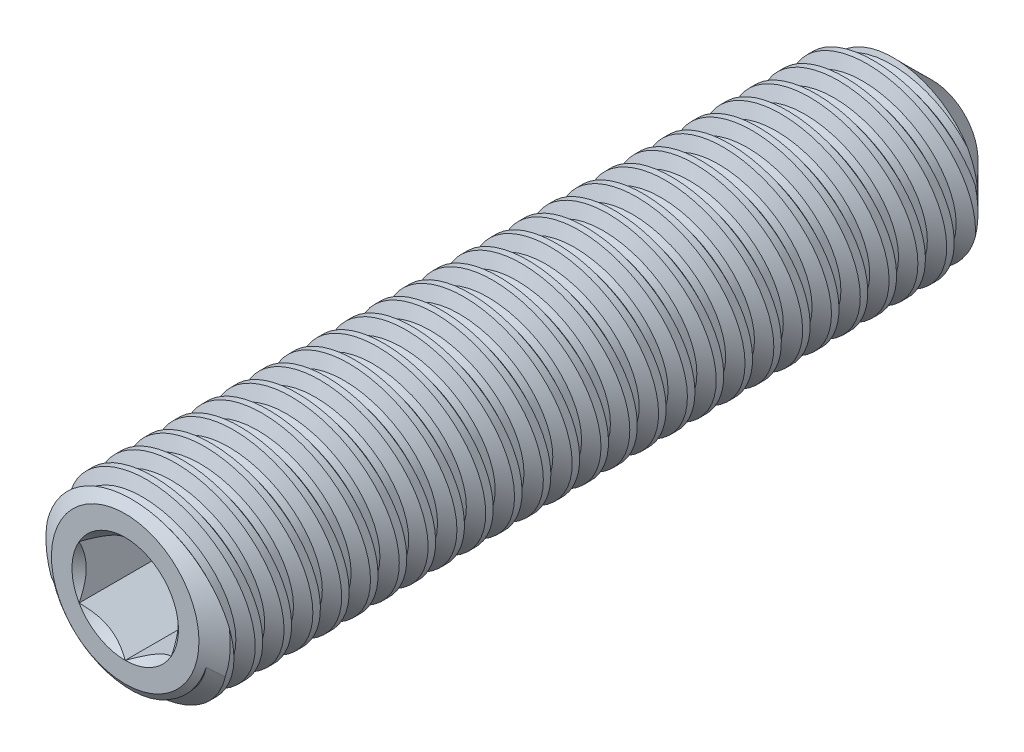
from build123d import *

# Parameters (mm, degrees)
LPATTERN1_COUNT     = 27
LPATTERN1_PITCH     = 1.25
LPATTERN1_COL_COUNT = 2
LPATTERN1_COL_PITCH = 1.25
CUT_EXTRUDE10_DEPTH = 4


with BuildPart() as part:
    # Sketch22 → Revolve1 (revolve)
    with BuildSketch(Plane(origin=(0, 0, 0), x_dir=(0, 0, -1), z_dir=(1, 0, 0)), mode=Mode.PRIVATE) as revolve1_sk:
        Polygon((-16.899139381, 0), (-16.899139381, 3.2), (-16.33897335, 4), (16.100860619, 4), (18.100860619, 2), (16.899139381, 0), align=None)
    revolve(revolve1_sk.sketch.rotate(Axis((0, 0, -16.899139381), (0, 0, -1)), 180), axis=Axis((0, 0, -16.899139381), (0, 0, -1)))

    # Sketch6 → Cut-Revolve8 (revolve, cut)
    with BuildSketch(Plane(origin=(0, 0, 0), x_dir=(0, 0, -1), z_dir=(1, 0, 0))):
        Polygon((15.092725821, 3.464196131), (14.78397206, 3.415953356), (14.293581187, 4.024121388), (15.374219349, 4.1929711), align=None)
    cut_revolve8 = revolve(axis=Axis((0, 0.208852549, -16.812516931), (0, -0.15437688027361343, 0.9880120337511009)), mode=Mode.SUBTRACT)

    # LPattern1: Cut-Revolve8 ×27
    with Locations(*[(0, 0, i * LPATTERN1_PITCH) for i in range(1, LPATTERN1_COUNT)]):
        add(cut_revolve8, mode=Mode.SUBTRACT)

    # LPattern1 col: Cut-Revolve8 ×2
    with Locations(*[(0, 0, -i * LPATTERN1_COL_PITCH) for i in range(1, LPATTERN1_COL_COUNT)]):
        add(cut_revolve8, mode=Mode.SUBTRACT)

    # Sketch23 → Cut-Extrude10 (cut)
    with BuildSketch(Plane.XY.offset(16.899139381)):
        Polygon((0, 2.309401077), (-2, 1.154700538), (-2, -1.154700538), (0, -2.309401077), (2, -1.154700538), (2, 1.154700538), align=None)
    extrude(amount=-CUT_EXTRUDE10_DEPTH, mode=Mode.SUBTRACT)

    # Cut-Extrude11 cone 1 section (through the dimple's axis) → Cut-Extrude11 (revolve, cut)
    with BuildSketch(Plane(origin=(0, 0, 16.899139381), x_dir=(0, -1, 0), z_dir=(1, 0, 0))):
        Polygon((0, 0), (2.309401077, 0), (0, 2.309401077), align=None)
    revolve(axis=Axis((0, 0, 16.899139381), (0, 0, -1)), mode=Mode.SUBTRACT)

    # Cut-Extrude12 cone 1 section (through the dimple's axis) → Cut-Extrude12 (revolve, cut)
    with BuildSketch(Plane(origin=(0, 0, 12.899139381), x_dir=(0, -1, 0), z_dir=(1, 0, 0))):
        Polygon((0, 0), (2, 0), (0, 1.201721238), align=None)
    revolve(axis=Axis((0, 0, 12.899139381), (0, 0, -1)), mode=Mode.SUBTRACT)


solid = part.part
